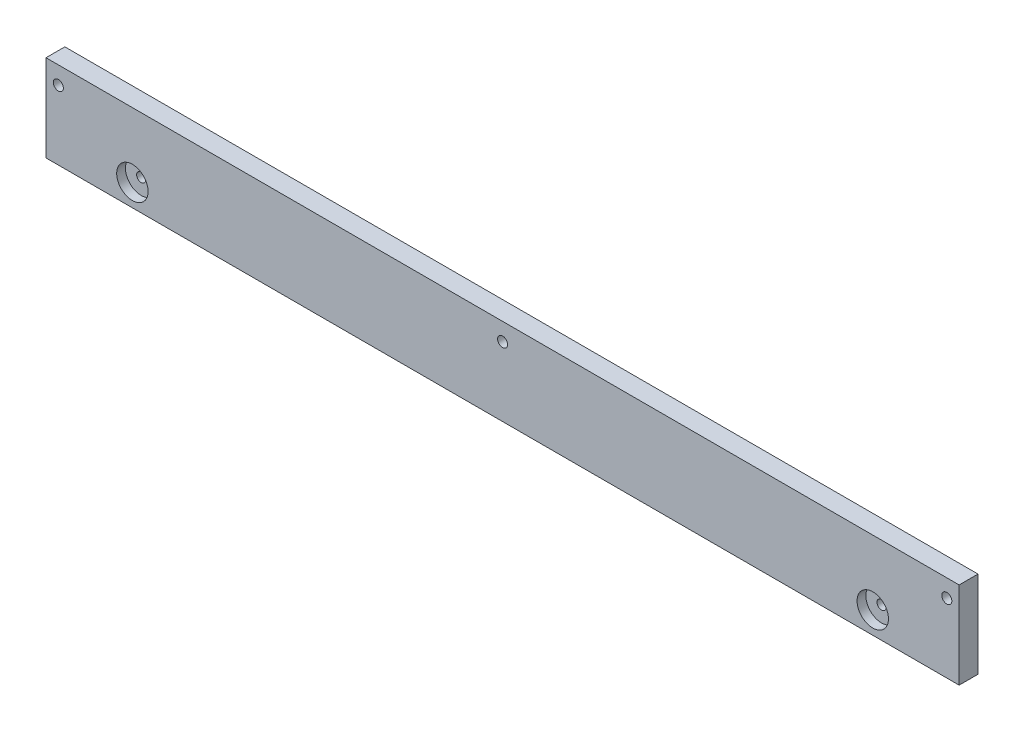
from build123d import *

# Parameters (mm, degrees)
ESQUISSE5_W             = 290.597320494
ESQUISSE5_H             = 27.625
ESQUISSE5_R             = 1.6
EXTRUSION1_DEPTH        = 6
ESQUISSE4_R             = 5
ENL_V_MAT_EXTRU_2_DEPTH = 2.8
ESQUISSE6_R             = 1.45
ENL_V_MAT_EXTRU_3_DEPTH = 2.5


with BuildPart() as part:
    # Esquisse5 → Extrusion1 (new body)
    with BuildSketch(Plane.XY):
        with Locations((141.37166943, 13.8125)):
            Rectangle(ESQUISSE5_W, ESQUISSE5_H)
        with Locations((282.74333886, 22)):
            Circle(ESQUISSE5_R, mode=Mode.SUBTRACT)
        with Locations((0, 22)):
            Circle(ESQUISSE5_R, mode=Mode.SUBTRACT)
        with Locations((141.37315521, 22)):
            Circle(ESQUISSE5_R, mode=Mode.SUBTRACT)
    extrude(amount=EXTRUSION1_DEPTH)

    # Esquisse4 → Enlèv. mat.-Extru.2 (cut)
    with BuildSketch(Plane.XY.offset(6)):
        with Locations((23.561944905, 7)):
            Circle(ESQUISSE4_R)
        with Locations((259.181393955, 7)):
            Circle(ESQUISSE4_R)
    extrude(amount=-ENL_V_MAT_EXTRU_2_DEPTH, mode=Mode.SUBTRACT)

    # Esquisse6 → Enlèv. mat.-Extru.3 (cut)
    with BuildSketch(Plane.XY.offset(3.2)):
        with Locations((23.561944905, 7)):
            Circle(ESQUISSE6_R)
        with Locations((259.181393955, 7)):
            Circle(ESQUISSE6_R)
    extrude(amount=-ENL_V_MAT_EXTRU_3_DEPTH, mode=Mode.SUBTRACT)


solid = part.part
